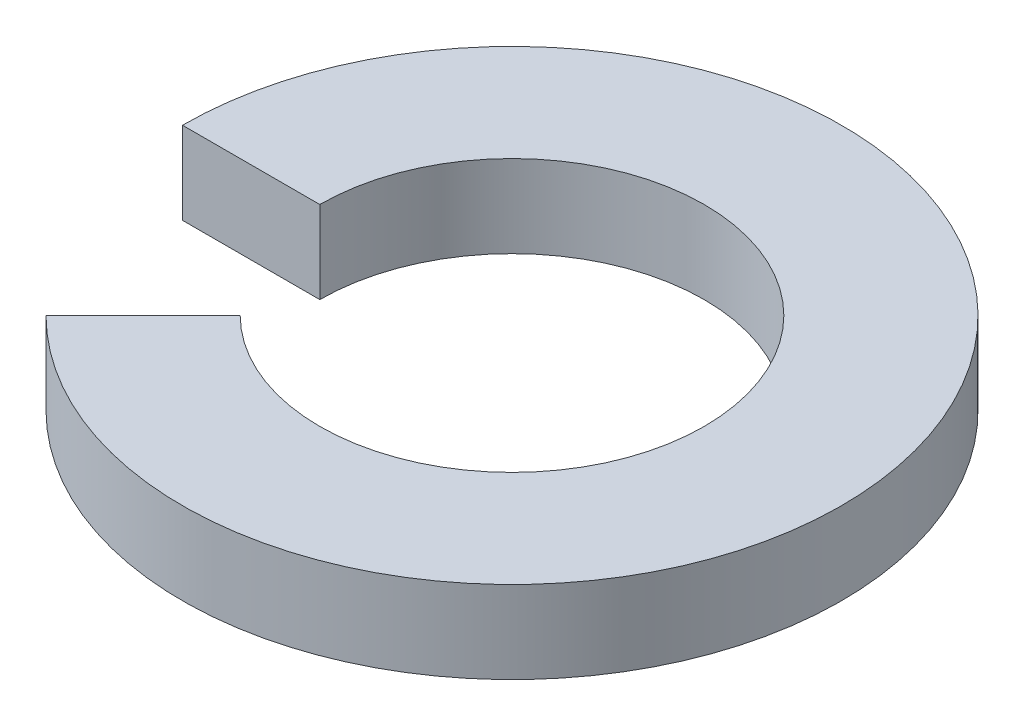
from build123d import *

# Parameters (mm, degrees)
BOSS_EXTRUDE1_DEPTH = 1.5


with BuildPart() as part:
    # Sketch1 → Boss-Extrude1 (new body)
    with BuildSketch(Plane(origin=(0, 0, 0), x_dir=(1, 0, 0), z_dir=(0, 1, 0))):
        with BuildLine():
            Line((-6, 0), (-3.5, 0))
            ThreePointArc((-3.5, 0), (3.233578364, 1.339392013), (-2.474873734, -2.474873734))
            Line((-2.474873734, -2.474873734), (-4.242640687, -4.242640687))
            ThreePointArc((-4.242640687, -4.242640687), (5.543277195, 2.296100594), (-6, 0))
        make_face()
    extrude(amount=BOSS_EXTRUDE1_DEPTH)


solid = part.part
